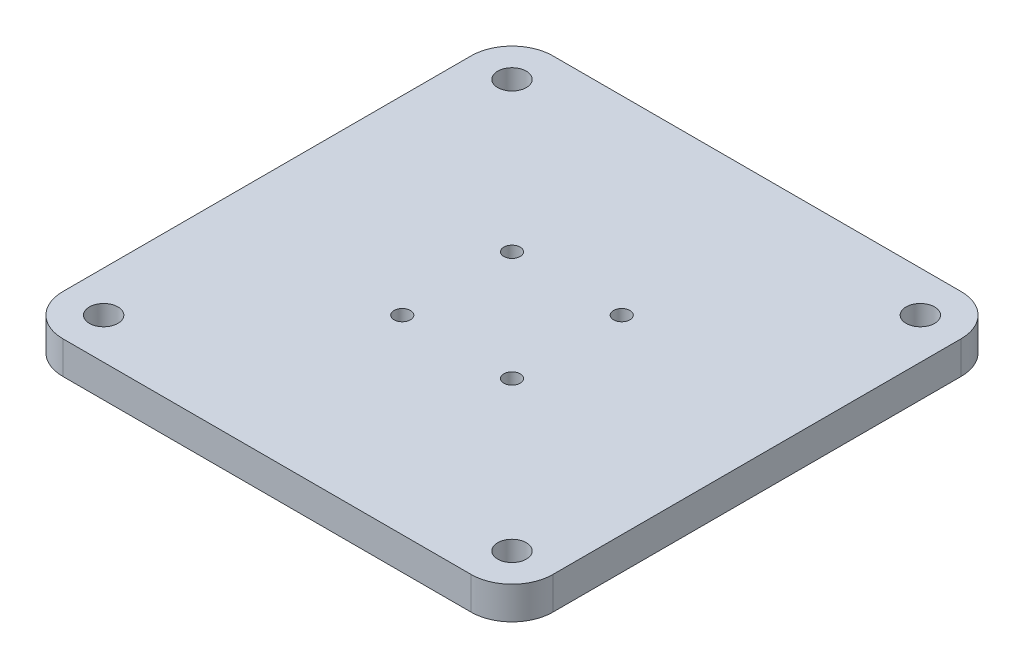
from build123d import *

# Parameters (mm, degrees)
SKETCH_1_W          = 120
SKETCH_1_H          = 120
SKETCH_1_R          = 2
EXTRUDE_1_DEPTH     = 8
SKETCH_2_R          = 3.5
CUT_EXTRUDE_1_DEPTH = 10
SKETCH_3_R          = 3.5
CUT_EXTRUDE_2_DEPTH = 4
FILLET_1_R          = 10


with BuildPart() as part:
    # 草图1 → 凸台-拉伸1 (new body)
    with BuildSketch(Plane(origin=(0, 0, 0), x_dir=(1, 0, 0), z_dir=(0, 1, 0))):
        Rectangle(SKETCH_1_W, SKETCH_1_H)
        with Locations((-13.435028843, 13.435028843)):
            Circle(SKETCH_1_R, mode=Mode.SUBTRACT)
        with Locations((13.435028843, 13.435028843)):
            Circle(SKETCH_1_R, mode=Mode.SUBTRACT)
        with Locations((13.435028843, -13.435028843)):
            Circle(SKETCH_1_R, mode=Mode.SUBTRACT)
        with Locations((-13.435028843, -13.435028843)):
            Circle(SKETCH_1_R, mode=Mode.SUBTRACT)
    extrude(amount=EXTRUDE_1_DEPTH)

    # 草图2 → 切除-拉伸1 (cut)
    with BuildSketch(Plane(origin=(0, 8, 0), x_dir=(1, 0, 0), z_dir=(0, 1, 0))):
        with Locations((-50, 50)):
            Circle(SKETCH_2_R)
        with Locations((50, 50)):
            Circle(SKETCH_2_R)
        with Locations((50, -50)):
            Circle(SKETCH_2_R)
        with Locations((-50, -50)):
            Circle(SKETCH_2_R)
    extrude(amount=-CUT_EXTRUDE_1_DEPTH, mode=Mode.SUBTRACT)

    # 草图3 → 切除-拉伸2 (cut)
    with BuildSketch(Plane.XZ):
        with Locations((-13.435028843, 13.435028843)):
            Circle(SKETCH_3_R)
        with Locations((13.435028843, 13.435028843)):
            Circle(SKETCH_3_R)
        with Locations((-13.435028843, -13.435028843)):
            Circle(SKETCH_3_R)
        with Locations((13.435028843, -13.435028843)):
            Circle(SKETCH_3_R)
    extrude(amount=-CUT_EXTRUDE_2_DEPTH, mode=Mode.SUBTRACT)

    # 圆角1
    fillet_1_edges = [part.edges().sort_by_distance(p)[0] for p in [
        (60, 4, 60),
        (-60, 4, 60),
        (-60, 4, -60),
        (60, 4, -60),
    ]]
    fillet(fillet_1_edges, radius=FILLET_1_R)


solid = part.part
